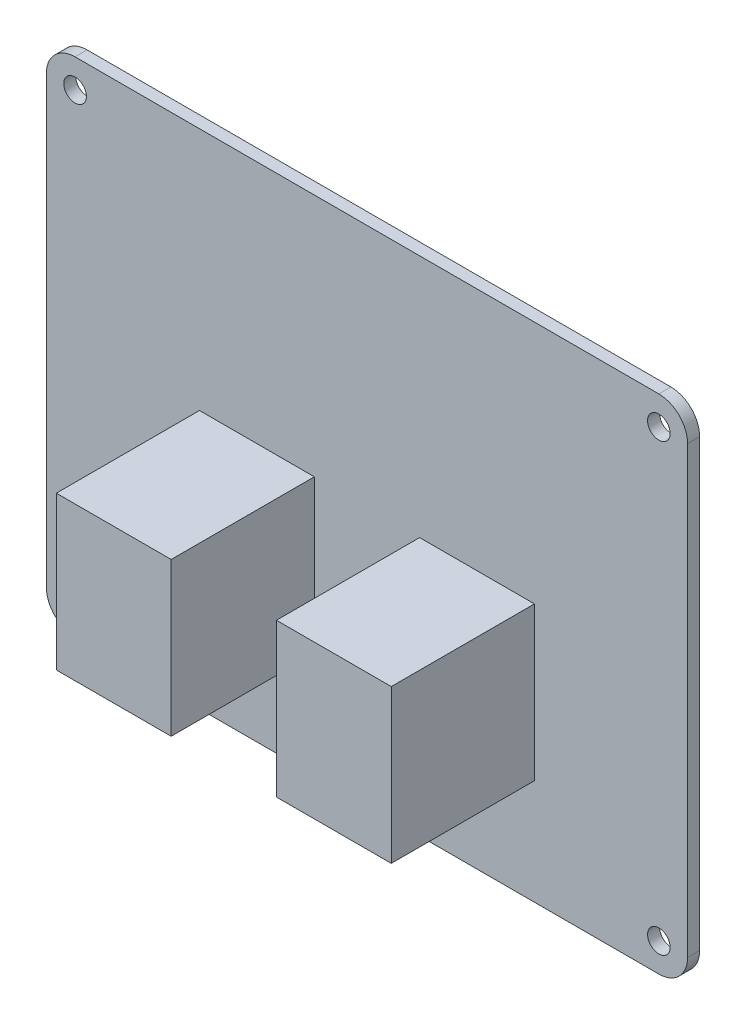
from build123d import *

# Parameters (mm, degrees)
SKETCH_1_W                = 85.09
SKETCH_1_H                = 66.675
EXTRUDE_1_DEPTH           = 1.6
SKETCH_2_W                = 15.24
SKETCH_2_H                = 20.32
EXTRUDE_2_DEPTH           = 19
SKETCH_3_W                = 15.24
SKETCH_3_H                = 20.32
EXTRUDE_3_DEPTH           = 19
HOLE_WIZARD_3_0_3_1_D     = 3
HOLE_WIZARD_3_0_3_1_DEPTH = 20.6
FILLET_1_R                = 3.81


with BuildPart() as part:
    # 草图1 → 凸台-拉伸1 (new body)
    with BuildSketch(Plane.XY.offset(1.6)):
        with Locations((42.545, 33.3375)):
            Rectangle(SKETCH_1_W, SKETCH_1_H)
    extrude(amount=-EXTRUDE_1_DEPTH)

    # 草图2 → 凸台-拉伸2 (add)
    with BuildSketch(Plane.XY.offset(1.6)):
        with Locations((57.15, 24.13)):
            Rectangle(SKETCH_2_W, SKETCH_2_H)
    extrude(amount=EXTRUDE_2_DEPTH)

    # 草图3 → 凸台-拉伸3 (add)
    with BuildSketch(Plane.XY.offset(1.6)):
        with Locations((27.94, 24.13)):
            Rectangle(SKETCH_3_W, SKETCH_3_H)
    extrude(amount=EXTRUDE_3_DEPTH)

    # Ø3.0 (3) 直径孔1
    with Locations(Plane(origin=(0, 0, 0), x_dir=(-1, 0, 0), z_dir=(0, 0, -1))):
        with Locations((-3.81, 62.865), (-3.81, 3.81), (-81.28, 3.81), (-81.28, 62.865)):
            Hole(HOLE_WIZARD_3_0_3_1_D / 2, depth=HOLE_WIZARD_3_0_3_1_DEPTH)

    # 圆角1
    fillet_1_edges = [part.edges().sort_by_distance(p)[0] for p in [
        (0, 0, 0.8),
        (0, 66.675, 0.8),
        (85.09, 66.675, 0.8),
        (85.09, 0, 0.8),
    ]]
    fillet(fillet_1_edges, radius=FILLET_1_R)


solid = part.part
